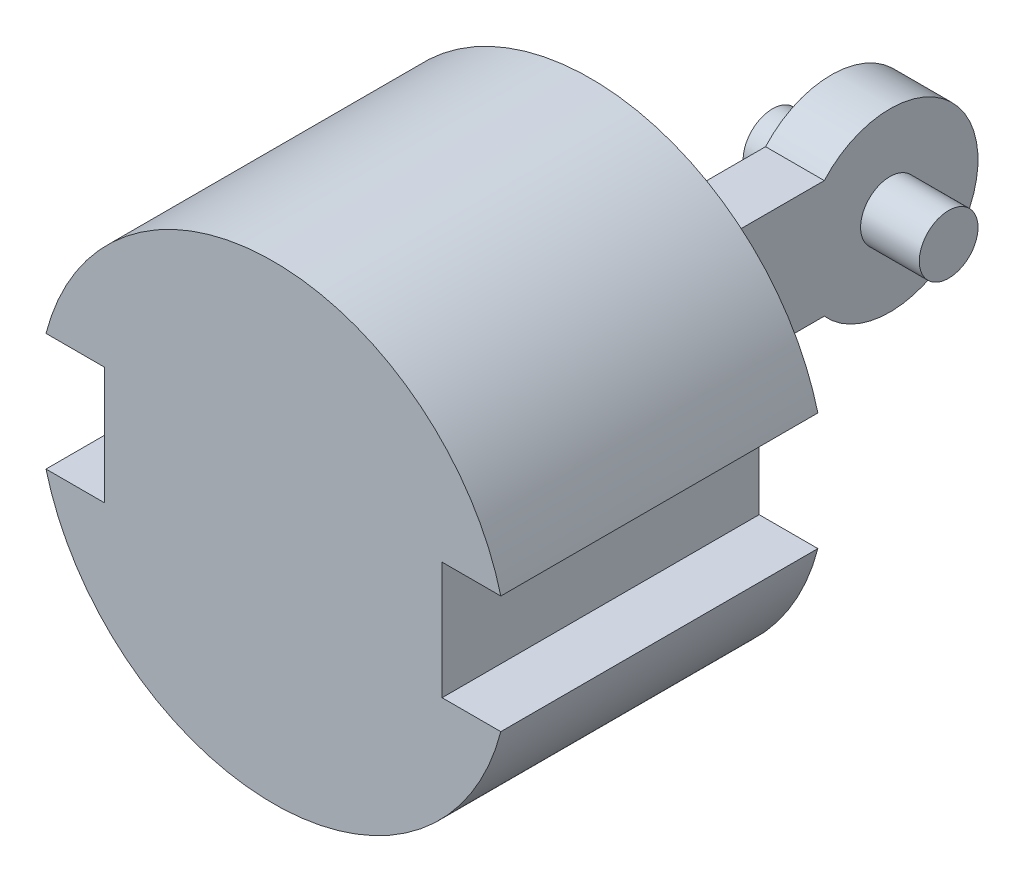
from build123d import *

# Parameters (mm, degrees)
BOSS_EXTRUDE1_DEPTH = 68.58
SKETCH3_R           = 6.35
BOSS_EXTRUDE2_DEPTH = 6.35
SKETCH3_3_R         = 6.35
BOSS_EXTRUDE3_DEPTH = 19.05


with BuildPart() as part:
    # Sketch1 → Boss-Extrude1 (new body)
    with BuildSketch(Plane.XY):
        with BuildLine():
            Line((-49.186888497, 12.7), (-36.486888497, 12.7))
            Line((-36.486888497, 12.7), (-36.486888497, -12.7))
            Line((-36.486888497, -12.7), (-49.186888497, -12.7))
            ThreePointArc((-49.186888497, -12.7), (0, -50.8), (49.186888497, -12.7))
            Line((49.186888497, -12.7), (36.486888497, -12.7))
            Line((36.486888497, -12.7), (36.486888497, 12.7))
            Line((36.486888497, 12.7), (49.186888497, 12.7))
            ThreePointArc((49.186888497, 12.7), (0, 50.8), (-49.186888497, 12.7))
        make_face()
    extrude(amount=BOSS_EXTRUDE1_DEPTH)

    # Sketch3 → Boss-Extrude2 (add, symmetric)
    with BuildSketch(Plane(origin=(0, 0, 0), x_dir=(0, 0, -1), z_dir=(1, 0, 0))):
        with BuildLine():
            Line((44.220968343, 12.7), (0, 12.7))
            Line((0, 12.7), (0, -12.7))
            Line((0, -12.7), (44.220968343, -12.7))
            ThreePointArc((44.220968343, -12.7), (77.47, 0), (44.220968343, 12.7))
        make_face()
        with Locations((58.42, 0)):
            Circle(SKETCH3_R, mode=Mode.SUBTRACT)
    extrude(amount=BOSS_EXTRUDE2_DEPTH, both=True)

    # Sketch3_3 → Boss-Extrude3 (add, symmetric)
    with BuildSketch(Plane(origin=(0, 0, 0), x_dir=(0, 0, -1), z_dir=(1, 0, 0))):
        with Locations((58.42, 0)):
            Circle(SKETCH3_3_R)
    extrude(amount=BOSS_EXTRUDE3_DEPTH, both=True)


solid = part.part
